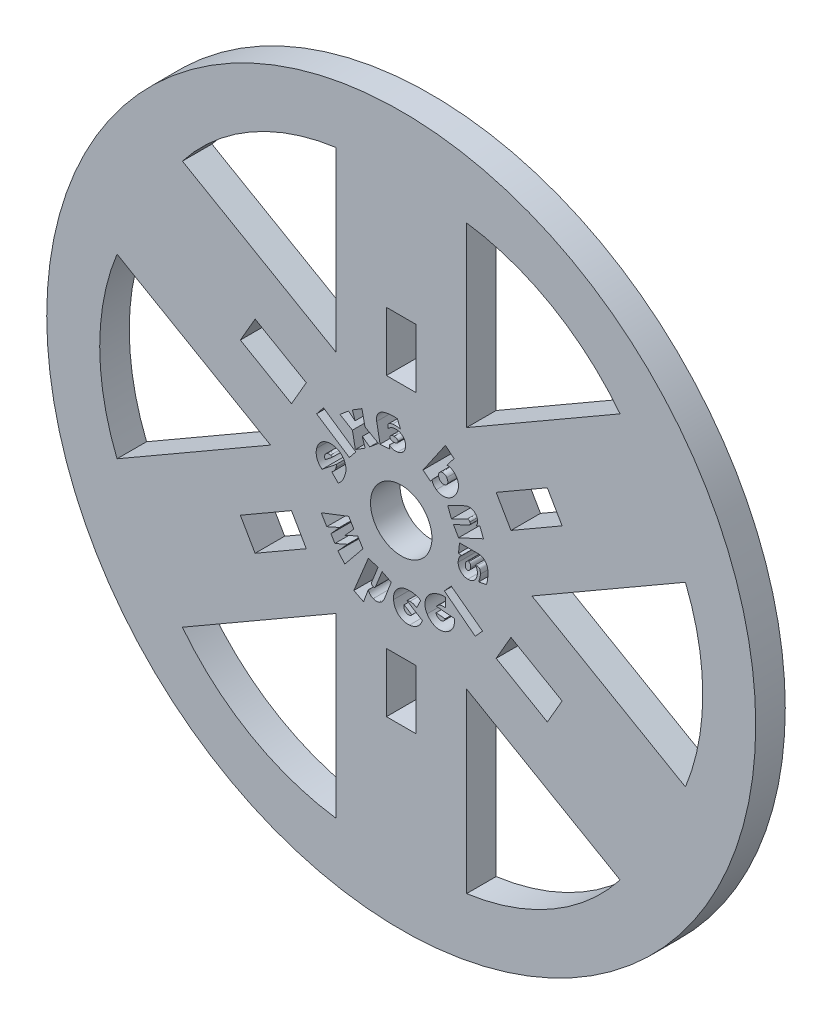
from build123d import *

# Parameters (mm, degrees)
SKETCH1_R          = 38.1
EXTRUDE1_DEPTH     = 3.175
SKETCH2_R          = 3.302
CUT_EXTRUDE1_DEPTH = 4.175
SKETCH3_W          = 3.175
SKETCH3_H          = 6.35
CUT_EXTRUDE2_DEPTH = 4.175
CUT_EXTRUDE3_DEPTH = 4.175
CUT_EXTRUDE4_DEPTH = 4.175


with BuildPart() as part:
    # Sketch1 → Extrude1 (new body)
    with BuildSketch(Plane.XY):
        Circle(SKETCH1_R)
    extrude(amount=EXTRUDE1_DEPTH)

    # Sketch2 → Cut-Extrude1 (cut, through all)
    with BuildSketch(Plane.XY.offset(3.175)):
        Circle(SKETCH2_R)
    extrude(amount=-CUT_EXTRUDE1_DEPTH, mode=Mode.SUBTRACT)

    # Sketch3 → Cut-Extrude2 (cut, through all)
    with BuildSketch(Plane.XY.offset(3.175)):
        with Locations((0, 15.875)):
            Rectangle(SKETCH3_W, SKETCH3_H)
        Polygon((-17.291533942, 8.150184671), (-15.704033942, 10.899815329), (-10.204772628, 7.724815329), (-11.792272628, 4.975184671), align=None)
        Polygon((-11.792272628, -4.975184671), (-10.204772628, -7.724815329), (-15.704033942, -10.899815329), (-17.291533942, -8.150184671), align=None)
        with Locations((0, -15.875)):
            Rectangle(SKETCH3_W, SKETCH3_H)
        Polygon((10.204772628, -7.724815329), (11.792272628, -4.975184671), (17.291533942, -8.150184671), (15.704033942, -10.899815329), align=None)
        Polygon((11.792272628, 4.975184671), (10.204772628, 7.724815329), (15.704033942, 10.899815329), (17.291533942, 8.150184671), align=None)
    extrude(amount=-CUT_EXTRUDE2_DEPTH, mode=Mode.SUBTRACT)

    # Sketch4 → Cut-Extrude3 (cut, through all)
    with BuildSketch(Plane.XY.offset(3.175)):
        with BuildLine():
            Line((7.02309032, 31.21434926), (7.02309032, 12.16434926))
            Line((7.02309032, 12.16434926), (23.520874262, 21.68934926))
            ThreePointArc((23.520874262, 21.68934926), (16.202768265, 28.064017859), (7.02309032, 31.21434926))
        make_face()
        with BuildLine():
            Line((30.543964582, 9.525), (14.04618064, 0))
            Line((14.04618064, 0), (30.543964582, -9.525))
            ThreePointArc((30.543964582, -9.525), (32.405536531, 0), (30.543964582, 9.525))
        make_face()
        with BuildLine():
            Line((23.520874262, -21.68934926), (7.02309032, -12.16434926))
            Line((7.02309032, -12.16434926), (7.02309032, -31.21434926))
            ThreePointArc((7.02309032, -31.21434926), (16.202768265, -28.064017859), (23.520874262, -21.68934926))
        make_face()
        with BuildLine():
            Line((-7.02309032, -31.21434926), (-7.02309032, -12.16434926))
            Line((-7.02309032, -12.16434926), (-23.520874262, -21.68934926))
            ThreePointArc((-23.520874262, -21.68934926), (-16.202768265, -28.064017859), (-7.02309032, -31.21434926))
        make_face()
        with BuildLine():
            Line((-30.543964582, -9.525), (-14.04618064, 0))
            Line((-14.04618064, 0), (-30.543964582, 9.525))
            ThreePointArc((-30.543964582, 9.525), (-32.405536531, 0), (-30.543964582, -9.525))
        make_face()
        with BuildLine():
            Line((-23.520874262, 21.68934926), (-7.02309032, 12.16434926))
            Line((-7.02309032, 12.16434926), (-7.02309032, 31.21434926))
            ThreePointArc((-7.02309032, 31.21434926), (-16.202768265, 28.064017859), (-23.520874262, 21.68934926))
        make_face()
    extrude(amount=-CUT_EXTRUDE3_DEPTH, mode=Mode.SUBTRACT)

    # Sketch5 → Cut-Extrude4 (cut, through all)
    with BuildSketch(Plane(origin=(0, 0, 0), x_dir=(-1, 0, 0), z_dir=(0, 0, -1))):
        with BuildLine():
            Line((6.770458386, 0.087976317), (7.468288285, 0.798603528))
            add(Edge.make_bspline(
                [(7.468288285, 0.798603528), (7.443432949, 0.816071539), (7.393779198, 0.850967557), (7.324020642, 0.909581033), (7.256485804, 0.971425153), (7.192046159, 1.038166748), (7.132118874, 1.113416826), (7.083642134, 1.201761147), (7.040063681, 1.300341562), (7.020679234, 1.371892512), (7.010596183, 1.409110592)],
                knots=[0, 0, 0, 0, 9.1099e-05, 0.00018199, 0.000273089, 0.000365733, 0.000460147, 0.000560614, 0.00066717, 0.00078268, 0.00078268, 0.00078268, 0.00078268], degree=3))
            add(Edge.make_bspline(
                [(7.010596183, 1.409110592), (7.004313634, 1.435914652), (6.991174223, 1.491973044), (6.976565307, 1.577084273), (6.968523466, 1.660128705), (6.977283986, 1.712281624), (6.981237644, 1.735818441)],
                knots=[0, 0, 0, 0, 8.2549e-05, 0.000172644, 0.000259375, 0.000330711, 0.000330711, 0.000330711, 0.000330711], degree=3))
            Line((6.981237644, 1.735818441), (8.505623346, 0.513298747))
            add(Edge.make_bspline(
                [(8.505623346, 0.513298747), (8.536892713, 0.537917212), (8.59872412, 0.586597262), (8.683756745, 0.667407906), (8.763170949, 0.751254325), (8.834811641, 0.840613307), (8.899695636, 0.934181701), (8.958024431, 1.032072776), (9.008140606, 1.135167048), (9.052983807, 1.241620671), (9.088984992, 1.352146806), (9.116088932, 1.465178438), (9.13435856, 1.580453726), (9.143165897, 1.697750932), (9.143483995, 1.81733511), (9.132919304, 1.93848591), (9.115533189, 2.062200229), (9.095979254, 2.144209658), (9.086019087, 2.185982713)],
                knots=[0, 0, 0, 0, 0.000119332, 0.000235965, 0.000351534, 0.000465572, 0.00057917, 0.00069291, 0.000807038, 0.000922793, 0.001039202, 0.001155326, 0.001271167, 0.001388948, 0.001507888, 0.00162948, 0.001753507, 0.00188227, 0.00188227, 0.00188227, 0.00188227], degree=3))
            add(Edge.make_bspline(
                [(9.086019087, 2.185982713), (9.071422161, 2.23724209), (9.042573392, 2.338549032), (8.982969933, 2.483518838), (8.912332231, 2.620751647), (8.8284284, 2.748360979), (8.734765815, 2.867089294), (8.629232195, 2.97379248), (8.513773118, 3.068987104), (8.388068194, 3.152123672), (8.253228429, 3.222926471), (8.109327236, 3.28066698), (7.956495356, 3.3231535), (7.79581487, 3.352587434), (7.627658551, 3.367385692), (7.452872694, 3.36289688), (7.271763068, 3.341321972), (7.150891825, 3.313082669), (7.088885622, 3.29859608)],
                knots=[0, 0, 0, 0, 0.000159783, 0.000315789, 0.000469322, 0.000622159, 0.000773231, 0.000922278, 0.001071483, 0.001221391, 0.001373589, 0.001527636, 0.001685636, 0.001848644, 0.002017123, 0.002191057, 0.002372291, 0.002563197, 0.002563197, 0.002563197, 0.002563197], degree=3))
            add(Edge.make_bspline(
                [(7.088885622, 3.29859608), (7.039323678, 3.284647443), (6.940900112, 3.256947266), (6.800714387, 3.196056861), (6.667363421, 3.124093705), (6.543319886, 3.038016016), (6.429135279, 2.940693748), (6.324376124, 2.834618596), (6.232423188, 2.717826014), (6.151663093, 2.592616454), (6.082924704, 2.45939083), (6.028054757, 2.318146269), (5.984862514, 2.170408096), (5.955505075, 2.015930918), (5.941023481, 1.856075853), (5.943468103, 1.691863792), (5.963043063, 1.524174215), (5.988288213, 1.412932501), (6.001114096, 1.356415778)],
                knots=[0, 0, 0, 0, 0.000154304, 0.000306428, 0.000457345, 0.000608317, 0.000758393, 0.000906913, 0.001054811, 0.001203483, 0.001353304, 0.00150372, 0.001657378, 0.001814466, 0.001974696, 0.002138065, 0.002306325, 0.002480094, 0.002480094, 0.002480094, 0.002480094], degree=3))
            add(Edge.make_bspline(
                [(6.001114096, 1.356415778), (6.01946971, 1.288868608), (6.055254323, 1.157184136), (6.123518122, 0.97005764), (6.199224575, 0.796980572), (6.286004679, 0.63775596), (6.384822656, 0.488542492), (6.499928701, 0.349016824), (6.626810223, 0.212620042), (6.721978619, 0.130042283), (6.770458386, 0.087976317)],
                knots=[0, 0, 0, 0, 0.000209908, 0.000409219, 0.00059694, 0.000776154, 0.000952577, 0.001132927, 0.001318243, 0.001510668, 0.001510668, 0.001510668, 0.001510668], degree=3))
        make_face()
        with BuildLine():
            Line((8.154073655, 1.592789659), (7.39075163, 2.201038374))
            add(Edge.make_bspline(
                [(7.39075163, 2.201038374), (7.402432849, 2.210707578), (7.424944062, 2.229341377), (7.455187998, 2.25115748), (7.483463301, 2.266396659), (7.511593467, 2.277326436), (7.546508933, 2.288698766), (7.572375665, 2.295301256), (7.586475226, 2.298900172)],
                knots=[0, 0, 0, 0, 4.5498e-05, 8.7681e-05, 0.000111593, 0.000141648, 0.00017807, 0.000221712, 0.000221712, 0.000221712, 0.000221712], degree=3))
            add(Edge.make_bspline(
                [(7.586475226, 2.298900172), (7.618450924, 2.305719808), (7.682682595, 2.319418855), (7.781821601, 2.316369945), (7.878817925, 2.29888569), (7.970388841, 2.264518449), (8.05476936, 2.216357615), (8.112822795, 2.16028213), (8.153622281, 2.110664088), (8.178306713, 2.068550194), (8.199207126, 2.023316752), (8.208213231, 1.99091792), (8.212790734, 1.974450672)],
                knots=[0, 0, 0, 0, 9.7769e-05, 0.000196395, 0.000295171, 0.000392352, 0.000488535, 0.000584402, 0.000632604, 0.000680887, 0.000730417, 0.000781612, 0.000781612, 0.000781612, 0.000781612], degree=3))
            add(Edge.make_bspline(
                [(8.212790734, 1.974450672), (8.22009815, 1.940490904), (8.234072655, 1.875547161), (8.233917721, 1.793150083), (8.224754003, 1.730248886), (8.207917921, 1.684252509), (8.18540939, 1.637330186), (8.164825182, 1.608071849), (8.154073655, 1.592789659)],
                knots=[0, 0, 0, 0, 0.00010396, 0.000198811, 0.000245344, 0.000293908, 0.000345081, 0.000401036, 0.000401036, 0.000401036, 0.000401036], degree=3))
        make_face(mode=Mode.SUBTRACT)
        Polygon((4.883680548, 3.940329055), (5.573982616, 3.082156363), (9.090232303, 5.389436451), (8.354010467, 6.316112401), align=None)
        Polygon((5.247492465, 7.670248568), (4.219943584, 8.303339123), (3.899257999, 6.771425591), (2.446386688, 5.950139269), (3.383601601, 5.157458704), (4.180046082, 5.738607228), (4.188326696, 5.732584964), (3.874416158, 4.799886749), (4.932076362, 4.137437654), (5.244481333, 5.79054926), (6.584435185, 6.578713126), (5.670556546, 7.361607512), (4.964446033, 6.797020215), (4.95616542, 6.803042479), align=None)
        with BuildLine():
            Line((1.224065456, 6.042364259), (2.273445046, 5.967085952))
            Line((2.273445046, 5.967085952), (2.636286482, 7.907007905))
            add(Edge.make_bspline(
                [(2.636286482, 7.907007905), (2.643729032, 7.956580103), (2.658071611, 8.052110955), (2.659977225, 8.192399211), (2.647306066, 8.322787293), (2.617396757, 8.443116222), (2.574017736, 8.553770533), (2.519268941, 8.656049454), (2.454708233, 8.750762912), (2.378288758, 8.836090892), (2.293308404, 8.914276753), (2.197481528, 8.982319384), (2.094059673, 9.043955631), (1.981888079, 9.095901465), (1.8645151, 9.140145743), (1.744149438, 9.179227503), (1.621131086, 9.210086751), (1.537575822, 9.224635529), (1.495820142, 9.231906096)],
                knots=[0, 0, 0, 0, 0.000150234, 0.000289518, 0.000419703, 0.000542213, 0.000660198, 0.000775374, 0.000889591, 0.001003182, 0.001118281, 0.001235283, 0.001355091, 0.001479017, 0.001605541, 0.00173124, 0.001858496, 0.001985618, 0.001985618, 0.001985618, 0.001985618], degree=3))
            add(Edge.make_bspline(
                [(1.495820142, 9.231906096), (1.40384902, 9.244937071), (1.221161709, 9.270821217), (0.992221367, 9.288489494), (0.811068175, 9.293699016), (0.677419437, 9.292647666), (0.545306352, 9.284159919), (0.458200558, 9.274403664), (0.414823664, 9.269545249)],
                knots=[0, 0, 0, 0, 0.000278624, 0.000553447, 0.000688248, 0.000822251, 0.000954248, 0.001085183, 0.001085183, 0.001085183, 0.001085183], degree=3))
            Line((0.414823664, 9.269545249), (0.085104682, 8.481381382))
            add(Edge.make_bspline(
                [(0.085104682, 8.481381382), (0.154559771, 8.490577332), (0.291963454, 8.508769771), (0.464240635, 8.525418818), (0.602463756, 8.532198429), (0.708809818, 8.530605966), (0.818135632, 8.522278499), (0.891631266, 8.512131639), (0.928974496, 8.506976006)],
                knots=[0, 0, 0, 0, 0.000210179, 0.000415799, 0.000519029, 0.000625182, 0.000734649, 0.000847722, 0.000847722, 0.000847722, 0.000847722], degree=3))
            add(Edge.make_bspline(
                [(0.928974496, 8.506976006), (0.968022628, 8.49991601), (1.042633824, 8.486426125), (1.147351531, 8.455748674), (1.238866588, 8.416659844), (1.306376019, 8.377591232), (1.351775925, 8.340397171), (1.379415089, 8.307992559), (1.401432038, 8.271692262), (1.417310729, 8.230887352), (1.427719496, 8.186027876), (1.432915749, 8.137002574), (1.432093269, 8.083676446), (1.426977508, 8.047236899), (1.424305751, 8.028205978)],
                knots=[0, 0, 0, 0, 0.000118992, 0.000227364, 0.000326506, 0.000417006, 0.000460283, 0.000501925, 0.000544141, 0.000587056, 0.000632704, 0.000681918, 0.000734618, 0.000792229, 0.000792229, 0.000792229, 0.000792229], degree=3))
            Line((1.424305751, 8.028205978), (1.39946391, 7.873132667))
            add(Edge.make_bspline(
                [(1.39946391, 7.873132667), (1.382206663, 7.89102346), (1.346891885, 7.927634707), (1.286436969, 7.977809097), (1.2203364, 8.027237269), (1.148067074, 8.07639916), (1.066408263, 8.120198958), (0.974189621, 8.157446491), (0.871043345, 8.186278391), (0.798114823, 8.199677341), (0.76035109, 8.206615564)],
                knots=[0, 0, 0, 0, 7.4522e-05, 0.000152499, 0.000235305, 0.00032216, 0.000414442, 0.000512715, 0.000619943, 0.000735097, 0.000735097, 0.000735097, 0.000735097], degree=3))
            add(Edge.make_bspline(
                [(0.76035109, 8.206615564), (0.723027778, 8.211633946), (0.64960952, 8.221505548), (0.539645997, 8.223188324), (0.432566133, 8.215915504), (0.328688367, 8.198692062), (0.229217304, 8.171823079), (0.133870995, 8.13878457), (0.044743741, 8.094829081), (-0.039741518, 8.045084099), (-0.117408966, 7.986407773), (-0.189607186, 7.921742862), (-0.254249877, 7.848759558), (-0.313096958, 7.770102153), (-0.3640245, 7.68486412), (-0.404401438, 7.592926664), (-0.436935844, 7.495804878), (-0.449193545, 7.427937532), (-0.455393557, 7.393609856)],
                knots=[0, 0, 0, 0, 0.000112892, 0.000222069, 0.000329229, 0.000434546, 0.000537347, 0.000638066, 0.000736715, 0.000834961, 0.000931769, 0.001028234, 0.001125258, 0.001223723, 0.001322616, 0.001422362, 0.001524488, 0.001629014, 0.001629014, 0.001629014, 0.001629014], degree=3))
            add(Edge.make_bspline(
                [(-0.455393557, 7.393609856), (-0.460788381, 7.354034261), (-0.471374176, 7.276378506), (-0.47202613, 7.160809975), (-0.463605304, 7.049303197), (-0.443016711, 6.94242418), (-0.41285448, 6.840707779), (-0.374284791, 6.74480534), (-0.328342552, 6.65458563), (-0.274061139, 6.57065932), (-0.211462844, 6.493914314), (-0.14166729, 6.424269028), (-0.065169781, 6.361281404), (0.018125598, 6.305954977), (0.106997629, 6.258228112), (0.200819659, 6.220274841), (0.298009315, 6.189089886), (0.365211905, 6.177114071), (0.39901522, 6.171090162)],
                knots=[0, 0, 0, 0, 0.000119709, 0.000234895, 0.000345922, 0.000454732, 0.000560725, 0.000663749, 0.000764414, 0.000864012, 0.000963005, 0.001060948, 0.001159358, 0.001259784, 0.00136048, 0.001461411, 0.001563082, 0.001665982, 0.001665982, 0.001665982, 0.001665982], degree=3))
            add(Edge.make_bspline(
                [(0.39901522, 6.171090162), (0.439846682, 6.165599551), (0.520259304, 6.154786456), (0.640504689, 6.151232134), (0.757799471, 6.158332057), (0.872174601, 6.173778903), (0.982711247, 6.203550237), (1.086275352, 6.250667309), (1.183253053, 6.3140413), (1.239640396, 6.367384431), (1.268479657, 6.394666732)],
                knots=[0, 0, 0, 0, 0.000123534, 0.000243286, 0.000360164, 0.000475779, 0.00058901, 0.000702211, 0.000815791, 0.000934695, 0.000934695, 0.000934695, 0.000934695], degree=3))
            Line((1.268479657, 6.394666732), (1.27901862, 6.393161166))
            Line((1.27901862, 6.393161166), (1.224065456, 6.042364259))
        make_face()
        with BuildLine():
            add(Edge.make_bspline(
                [(0.773148402, 7.449315803), (0.807849254, 7.448757833), (0.872906985, 7.447711741), (0.963348222, 7.432183313), (1.039957146, 7.405975136), (1.100177201, 7.366579228), (1.146396019, 7.321910564), (1.180540588, 7.275050752), (1.201766068, 7.225407423), (1.204605016, 7.191295579), (1.205998663, 7.174549985)],
                knots=[0, 0, 0, 0, 0.000103982, 0.000194948, 0.000274247, 0.000345033, 0.000408918, 0.000466149, 0.000518151, 0.000568295, 0.000568295, 0.000568295, 0.000568295], degree=3))
            add(Edge.make_bspline(
                [(1.205998663, 7.174549985), (1.205028493, 7.155788897), (1.203092542, 7.118351575), (1.18124133, 7.064758189), (1.145014613, 7.016086759), (1.094942916, 6.972918668), (1.032242051, 6.936322242), (0.956634272, 6.912624932), (0.870737127, 6.895966141), (0.809377593, 6.895016919), (0.776912317, 6.894514686)],
                knots=[0, 0, 0, 0, 5.6031e-05, 0.000111808, 0.00017053, 0.000236672, 0.000308849, 0.000386692, 0.000473213, 0.000570427, 0.000570427, 0.000570427, 0.000570427], degree=3))
            add(Edge.make_bspline(
                [(0.776912317, 6.894514686), (0.744205917, 6.895081804), (0.682411449, 6.896153301), (0.595304864, 6.912066953), (0.518349197, 6.934774442), (0.453854108, 6.969876389), (0.401595695, 7.011858872), (0.363574279, 7.060723072), (0.340217835, 7.115691031), (0.336773431, 7.15425999), (0.335028659, 7.173797202)],
                knots=[0, 0, 0, 0, 9.7966e-05, 0.000185094, 0.00026485, 0.000337605, 0.000403919, 0.000464596, 0.000521634, 0.000580187, 0.000580187, 0.000580187, 0.000580187], degree=3))
            add(Edge.make_bspline(
                [(0.335028659, 7.173797202), (0.336868552, 7.193407426), (0.34053557, 7.232491782), (0.367415674, 7.286852626), (0.409128541, 7.335058851), (0.466001032, 7.37513629), (0.532857608, 7.408419025), (0.607467088, 7.432478897), (0.688258691, 7.447141252), (0.744226712, 7.44857494), (0.773148402, 7.449315803)],
                knots=[0, 0, 0, 0, 5.8664e-05, 0.000116921, 0.000178322, 0.000248335, 0.000324082, 0.000401689, 0.000482755, 0.000569443, 0.000569443, 0.000569443, 0.000569443], degree=3))
        make_face(mode=Mode.SUBTRACT)
        with BuildLine():
            Line((-4.743809668, 9.369816882), (-5.676507883, 8.608000422))
            Line((-5.676507883, 8.608000422), (-4.928994301, 7.613573996))
            add(Edge.make_bspline(
                [(-4.928994301, 7.613573996), (-4.955327562, 7.615383055), (-5.008007186, 7.619002073), (-5.087673462, 7.614423531), (-5.167147993, 7.599782248), (-5.246138084, 7.576181251), (-5.323476376, 7.545170105), (-5.399749505, 7.509443435), (-5.47397744, 7.468597973), (-5.521159885, 7.436782553), (-5.544770847, 7.420861532)],
                knots=[0, 0, 0, 0, 7.9132e-05, 0.000158303, 0.000238629, 0.000321044, 0.000405198, 0.000488376, 0.00057363, 0.000659027, 0.000659027, 0.000659027, 0.000659027], degree=3))
            add(Edge.make_bspline(
                [(-5.544770847, 7.420861532), (-5.589969605, 7.387696733), (-5.678138176, 7.323002634), (-5.794526613, 7.211821221), (-5.895203349, 7.093960013), (-5.977927931, 6.967900894), (-6.044246417, 6.836587569), (-6.095269917, 6.701310683), (-6.130872214, 6.562491548), (-6.150294172, 6.420287978), (-6.154655598, 6.275989153), (-6.144561818, 6.130340805), (-6.121069008, 5.983162156), (-6.083229028, 5.835386783), (-6.032363075, 5.688201556), (-5.967382867, 5.543961706), (-5.891944399, 5.401639009), (-5.831867873, 5.311335908), (-5.801469871, 5.265643623)],
                knots=[0, 0, 0, 0, 0.000168033, 0.000327779, 0.000481612, 0.000632148, 0.000778931, 0.000922104, 0.001065064, 0.001207934, 0.001351786, 0.001497403, 0.001645295, 0.001798296, 0.001954469, 0.002111845, 0.002272499, 0.002437047, 0.002437047, 0.002437047, 0.002437047], degree=3))
            add(Edge.make_bspline(
                [(-5.801469871, 5.265643623), (-5.765955573, 5.216774244), (-5.696681975, 5.12145045), (-5.580452555, 4.993148598), (-5.459350387, 4.880050959), (-5.331614278, 4.78409497), (-5.199912598, 4.704785856), (-5.066696085, 4.638989608), (-4.931661612, 4.589203365), (-4.795404275, 4.554322437), (-4.659145786, 4.534056079), (-4.523525254, 4.527400204), (-4.388787428, 4.532936507), (-4.255938341, 4.553597594), (-4.126357977, 4.586667106), (-4.001949611, 4.631796305), (-3.883167508, 4.689109682), (-3.809647008, 4.736648593), (-3.772719517, 4.760526188)],
                knots=[0, 0, 0, 0, 0.000181121, 0.000353291, 0.000518427, 0.000677565, 0.000831584, 0.000979045, 0.001122661, 0.001262517, 0.001400278, 0.001535197, 0.001669327, 0.001804111, 0.001937759, 0.002069926, 0.002200555, 0.002332378, 0.002332378, 0.002332378, 0.002332378], degree=3))
            add(Edge.make_bspline(
                [(-3.772719517, 4.760526188), (-3.743189956, 4.782078941), (-3.683797032, 4.82542808), (-3.60224764, 4.900209071), (-3.526523001, 4.98228329), (-3.456937778, 5.06984025), (-3.396769887, 5.162956023), (-3.353005063, 5.261172662), (-3.324548122, 5.362508182), (-3.318710701, 5.431332648), (-3.315780198, 5.465883918)],
                knots=[0, 0, 0, 0, 0.000109607, 0.000220453, 0.000331253, 0.000444353, 0.000555668, 0.000662828, 0.000765825, 0.000869657, 0.000869657, 0.000869657, 0.000869657], degree=3))
            Line((-3.315780198, 5.465883918), (-3.306746801, 5.472658965))
            Line((-3.306746801, 5.472658965), (-3.136617829, 5.228757253))
            Line((-3.136617829, 5.228757253), (-2.33565665, 5.867870073))
            Line((-2.33565665, 5.867870073), (-4.743809668, 9.369816882))
        make_face()
        with BuildLine():
            add(Edge.make_bspline(
                [(-4.113730244, 5.891206348), (-4.126245603, 5.874665413), (-4.150551259, 5.84254182), (-4.190912089, 5.799218707), (-4.233093527, 5.7615379), (-4.290295304, 5.719013063), (-4.365472391, 5.677837621), (-4.460404317, 5.64875069), (-4.555562171, 5.640293942), (-4.648148028, 5.646920489), (-4.736956857, 5.673307497), (-4.789059775, 5.705067596), (-4.815324059, 5.721077376)],
                knots=[0, 0, 0, 0, 6.2195e-05, 0.000120786, 0.0001773, 0.000231652, 0.000334387, 0.000432737, 0.000527267, 0.000619415, 0.000709905, 0.000801887, 0.000801887, 0.000801887, 0.000801887], degree=3))
            add(Edge.make_bspline(
                [(-4.815324059, 5.721077376), (-4.838831301, 5.73971497), (-4.886853379, 5.777789023), (-4.942276637, 5.853462454), (-4.984067897, 5.938691226), (-5.007098813, 6.032922524), (-5.009938692, 6.132304908), (-4.998504299, 6.217348823), (-4.980707576, 6.286733308), (-4.957655121, 6.338461772), (-4.931319427, 6.391296112), (-4.907896212, 6.423966539), (-4.895871846, 6.440737984)],
                knots=[0, 0, 0, 0, 8.9654e-05, 0.000183151, 0.000278433, 0.000373009, 0.000471695, 0.000574967, 0.000629568, 0.000685911, 0.000744498, 0.000806299, 0.000806299, 0.000806299, 0.000806299], degree=3))
            add(Edge.make_bspline(
                [(-4.895871846, 6.440737984), (-4.883865496, 6.456783972), (-4.86036312, 6.488193921), (-4.820889376, 6.530395121), (-4.779656768, 6.567674902), (-4.721689326, 6.608286563), (-4.645560684, 6.647011878), (-4.550370684, 6.67517683), (-4.454679786, 6.686014363), (-4.361398688, 6.675009224), (-4.272744909, 6.650469708), (-4.221086028, 6.619339453), (-4.195783598, 6.604091909)],
                knots=[0, 0, 0, 0, 6.0081e-05, 0.000117609, 0.00017306, 0.000226529, 0.000329547, 0.000427681, 0.000523035, 0.000616143, 0.000708075, 0.000796331, 0.000796331, 0.000796331, 0.000796331], degree=3))
            add(Edge.make_bspline(
                [(-4.195783598, 6.604091909), (-4.171149113, 6.584815752), (-4.121976328, 6.546338703), (-4.067118766, 6.469987701), (-4.025682812, 6.385495363), (-4.004550009, 6.291860947), (-4.000538549, 6.193006697), (-4.014138183, 6.109337437), (-4.032036325, 6.041584594), (-4.054105126, 5.991172306), (-4.080060052, 5.939980618), (-4.102289657, 5.907779057), (-4.113730244, 5.891206348)],
                knots=[0, 0, 0, 0, 9.3409e-05, 0.000186453, 0.000279048, 0.000374179, 0.000472114, 0.000574104, 0.000627254, 0.000681917, 0.000738821, 0.000799161, 0.000799161, 0.000799161, 0.000799161], degree=3))
        make_face(mode=Mode.SUBTRACT)
        with BuildLine():
            Line((-8.448062244, 3.725970437), (-8.835745521, 2.715735567))
            Line((-8.835745521, 2.715735567), (-6.159601733, 1.47289073))
            Line((-6.159601733, 1.47289073), (-5.610070097, 2.434947484))
            Line((-5.610070097, 2.434947484), (-7.306090337, 3.228380833))
            add(Edge.make_bspline(
                [(-7.306090337, 3.228380833), (-7.320661648, 3.236195185), (-7.348758423, 3.251263021), (-7.381692441, 3.285324766), (-7.407180773, 3.324598126), (-7.420531339, 3.370815582), (-7.425441456, 3.418971298), (-7.423299224, 3.466972609), (-7.413558057, 3.513878893), (-7.401193279, 3.543213758), (-7.394918739, 3.558099814)],
                knots=[0, 0, 0, 0, 4.9317e-05, 9.5095e-05, 0.000140419, 0.000188514, 0.000237728, 0.000285207, 0.000332158, 0.00038053, 0.00038053, 0.00038053, 0.00038053], degree=3))
            add(Edge.make_bspline(
                [(-7.394918739, 3.558099814), (-7.386900224, 3.572992571), (-7.371261601, 3.602038129), (-7.339421251, 3.639337367), (-7.303305454, 3.670901173), (-7.261843231, 3.69379182), (-7.218444114, 3.709464302), (-7.173989155, 3.714373231), (-7.130044652, 3.707433571), (-7.103595486, 3.694803546), (-7.090041598, 3.688331284)],
                knots=[0, 0, 0, 0, 5.061e-05, 9.8706e-05, 0.000146227, 0.000193754, 0.000239938, 0.000283832, 0.000326529, 0.000371407, 0.000371407, 0.000371407, 0.000371407], degree=3))
            Line((-7.090041598, 3.688331284), (-5.396279707, 2.855753217))
            Line((-5.396279707, 2.855753217), (-4.994293551, 3.905885589))
            Line((-4.994293551, 3.905885589), (-6.803231251, 4.77610281))
            add(Edge.make_bspline(
                [(-6.803231251, 4.77610281), (-6.835656622, 4.790863835), (-6.899367262, 4.819866875), (-6.997123462, 4.854980665), (-7.095062876, 4.880094506), (-7.192085567, 4.898511661), (-7.288017438, 4.908541691), (-7.382068348, 4.909476947), (-7.474012647, 4.900853396), (-7.563421742, 4.884753462), (-7.649543567, 4.859092551), (-7.731766347, 4.824251823), (-7.809380235, 4.779489415), (-7.88298998, 4.725920496), (-7.950770942, 4.662295927), (-8.013334416, 4.58900375), (-8.069641391, 4.505509985), (-8.101371941, 4.444464002), (-8.117590479, 4.413261373)],
                knots=[0, 0, 0, 0, 0.000106855, 0.000209954, 0.000311107, 0.000409883, 0.000505986, 0.000600086, 0.000691549, 0.000782648, 0.000872201, 0.000960569, 0.001049925, 0.001140416, 0.00123309, 0.001328132, 0.001428977, 0.001534415, 0.001534415, 0.001534415, 0.001534415], degree=3))
            add(Edge.make_bspline(
                [(-8.117590479, 4.413261373), (-8.131974343, 4.381454551), (-8.160281955, 4.318858352), (-8.187850666, 4.220811889), (-8.207812156, 4.123035185), (-8.214809504, 4.022817055), (-8.207374077, 3.918156833), (-8.180869591, 3.808161668), (-8.139483043, 3.69044183), (-8.099993145, 3.612626126), (-8.079198543, 3.571649909)],
                knots=[0, 0, 0, 0, 0.00010458, 0.000205815, 0.00030473, 0.000403577, 0.000506232, 0.000618177, 0.000741986, 0.000879698, 0.000879698, 0.000879698, 0.000879698], degree=3))
            Line((-8.079198543, 3.571649909), (-8.088231939, 3.552830333))
            Line((-8.088231939, 3.552830333), (-8.448062244, 3.725970437))
        make_face()
        with BuildLine():
            Line((-6.146600771, 0.015202137), (-6.267798844, 1.058559462))
            Line((-6.267798844, 1.058559462), (-8.236326554, 1.054042764))
            add(Edge.make_bspline(
                [(-8.236326554, 1.054042764), (-8.286360316, 1.052168558), (-8.382728481, 1.04855872), (-8.520767288, 1.02499378), (-8.646158932, 0.987706857), (-8.758659438, 0.935827314), (-8.859184628, 0.872768404), (-8.949922032, 0.800816314), (-9.029714774, 0.718929062), (-9.100404489, 0.629107297), (-9.159687722, 0.530261382), (-9.210310767, 0.424730108), (-9.251137431, 0.311754823), (-9.281435776, 0.192610548), (-9.302459192, 0.06937491), (-9.318083833, -0.055425938), (-9.324676941, -0.181705571), (-9.323790722, -0.26608455), (-9.323345296, -0.30849458)],
                knots=[0, 0, 0, 0, 0.000150076, 0.000289056, 0.000418843, 0.000541451, 0.000659468, 0.000774094, 0.000888011, 0.001001703, 0.001116218, 0.001233055, 0.001352358, 0.001475966, 0.001601338, 0.001727204, 0.001853101, 0.001980321, 0.001980321, 0.001980321, 0.001980321], degree=3))
            add(Edge.make_bspline(
                [(-9.323345296, -0.30849458), (-9.318934885, -0.40113689), (-9.310179722, -0.585042314), (-9.286645563, -0.813170171), (-9.257110994, -0.991680231), (-9.231255321, -1.122731518), (-9.198903436, -1.250830652), (-9.172912688, -1.334396265), (-9.159991372, -1.375940963)],
                knots=[0, 0, 0, 0, 0.000278226, 0.000552311, 0.00068733, 0.000820938, 0.000952941, 0.001083449, 0.001083449, 0.001083449, 0.001083449], degree=3))
            Line((-9.159991372, -1.375940963), (-8.325907738, -1.552844982))
            add(Edge.make_bspline(
                [(-8.325907738, -1.552844982), (-8.348095772, -1.486217558), (-8.391911662, -1.354644844), (-8.44134125, -1.188819088), (-8.473245754, -1.054373705), (-8.491209085, -0.94981729), (-8.503259049, -0.841200682), (-8.50695732, -0.767468698), (-8.508834022, -0.730053095)],
                knots=[0, 0, 0, 0, 0.000210678, 0.000416038, 0.000518842, 0.000625027, 0.000734095, 0.000846464, 0.000846464, 0.000846464, 0.000846464], degree=3))
            add(Edge.make_bspline(
                [(-8.508834022, -0.730053095), (-8.509088724, -0.690382135), (-8.509575193, -0.614612349), (-8.498423851, -0.506573824), (-8.477622532, -0.409618482), (-8.451514761, -0.336560772), (-8.423709298, -0.284754711), (-8.396634282, -0.252167434), (-8.365304557, -0.223476192), (-8.328214394, -0.200377621), (-8.285815496, -0.182035396), (-8.238408542, -0.168939002), (-8.185962462, -0.159712442), (-8.14929505, -0.157556217), (-8.130184142, -0.156432401)],
                knots=[0, 0, 0, 0, 0.000118949, 0.000227188, 0.000325087, 0.000415837, 0.000458977, 0.000500714, 0.000542287, 0.000585936, 0.000631109, 0.000680432, 0.000733154, 0.000790543, 0.000790543, 0.000790543, 0.000790543], degree=3))
            Line((-8.130184142, -0.156432401), (-7.974358048, -0.15116292))
            add(Edge.make_bspline(
                [(-7.974358048, -0.15116292), (-7.988506886, -0.171519129), (-8.017479299, -0.213202302), (-8.055515214, -0.281935785), (-8.092203961, -0.355913446), (-8.126815833, -0.435992001), (-8.155256081, -0.523899279), (-8.173566809, -0.621203996), (-8.18340836, -0.727587311), (-8.182564459, -0.801547614), (-8.182126173, -0.839959422)],
                knots=[0, 0, 0, 0, 7.4328e-05, 0.0001522, 0.000235354, 0.000322042, 0.000413699, 0.000511876, 0.000618469, 0.000733647, 0.000733647, 0.000733647, 0.000733647], degree=3))
            add(Edge.make_bspline(
                [(-8.182126173, -0.839959422), (-8.180140761, -0.877431257), (-8.176228481, -0.951270002), (-8.1570344, -1.059370921), (-8.131623196, -1.163566071), (-8.094880493, -1.26235326), (-8.050883458, -1.355375774), (-7.99913853, -1.441870703), (-7.94119141, -1.521940225), (-7.876382641, -1.595337232), (-7.804498601, -1.660879746), (-7.726990904, -1.719154403), (-7.643282091, -1.768623417), (-7.55554908, -1.812367243), (-7.462106653, -1.844882599), (-7.364957176, -1.868995631), (-7.263532252, -1.88081703), (-7.194750064, -1.880977147), (-7.159846774, -1.881058398)],
                knots=[0, 0, 0, 0, 0.00011247, 0.000221623, 0.000328797, 0.000433823, 0.000537195, 0.00063712, 0.000735746, 0.000833333, 0.000930304, 0.001027112, 0.00112368, 0.001221652, 0.001320699, 0.001419841, 0.001521431, 0.001626092, 0.001626092, 0.001626092, 0.001626092], degree=3))
            add(Edge.make_bspline(
                [(-7.159846774, -1.881058398), (-7.120120425, -1.878837446), (-7.041979689, -1.87446889), (-6.928522008, -1.854573282), (-6.821148699, -1.825026949), (-6.72017218, -1.786052911), (-6.626327359, -1.737558682), (-6.538940182, -1.682715341), (-6.459977699, -1.619818898), (-6.387774625, -1.551101652), (-6.323746869, -1.475630342), (-6.267735215, -1.394278097), (-6.22119985, -1.306824428), (-6.181638907, -1.215128591), (-6.152152983, -1.119101096), (-6.130303139, -1.020525378), (-6.11996001, -0.919483132), (-6.120155271, -0.851519216), (-6.120253364, -0.81737593)],
                knots=[0, 0, 0, 0, 0.000119282, 0.000234625, 0.000344753, 0.000452955, 0.000558669, 0.000661208, 0.000761963, 0.000860994, 0.000959792, 0.001058346, 0.001156696, 0.00125653, 0.001357481, 0.001457587, 0.001559009, 0.001661399, 0.001661399, 0.001661399, 0.001661399], degree=3))
            add(Edge.make_bspline(
                [(-6.120253364, -0.81737593), (-6.122203012, -0.776396391), (-6.126049886, -0.695539182), (-6.145784821, -0.577040999), (-6.173393696, -0.462854667), (-6.210400761, -0.353552212), (-6.259673362, -0.25082271), (-6.324726428, -0.157924753), (-6.404231623, -0.074328026), (-6.467461297, -0.029469329), (-6.499656028, -0.006628571)],
                knots=[0, 0, 0, 0, 0.000122983, 0.000242659, 0.000359692, 0.000475152, 0.000588273, 0.000700205, 0.000814137, 0.000932326, 0.000932326, 0.000932326, 0.000932326], degree=3))
            Line((-6.499656028, -0.006628571), (-6.500408811, 0.003910391))
            Line((-6.500408811, 0.003910391), (-6.146600771, 0.015202137))
        make_face()
        with BuildLine():
            add(Edge.make_bspline(
                [(-7.442140422, -0.68714446), (-7.447741155, -0.65286547), (-7.458201806, -0.588841608), (-7.460654414, -0.497254874), (-7.448800924, -0.417431974), (-7.421832707, -0.350713896), (-7.386333333, -0.297377446), (-7.346717725, -0.255312424), (-7.302596282, -0.225037754), (-7.269847673, -0.215848129), (-7.253944657, -0.211385565)],
                knots=[0, 0, 0, 0, 0.000104118, 0.000194465, 0.000273793, 0.000344387, 0.000408484, 0.000464917, 0.000517115, 0.000566392, 0.000566392, 0.000566392, 0.000566392], degree=3))
            add(Edge.make_bspline(
                [(-7.253944657, -0.211385565), (-7.235122238, -0.208763801), (-7.197950499, -0.203586173), (-7.141136278, -0.215644291), (-7.086691651, -0.24223781), (-7.035090242, -0.283628415), (-6.986969526, -0.337800165), (-6.94931176, -0.407451661), (-6.91771359, -0.489048291), (-6.905246174, -0.549125504), (-6.898631051, -0.581002048)],
                knots=[0, 0, 0, 0, 5.6639e-05, 0.000111855, 0.000171114, 0.000237072, 0.000309092, 0.000386964, 0.000473223, 0.000570725, 0.000570725, 0.000570725, 0.000570725], degree=3))
            add(Edge.make_bspline(
                [(-6.898631051, -0.581002048), (-6.893615663, -0.61303747), (-6.884055139, -0.674104618), (-6.882074286, -0.762502277), (-6.892262583, -0.842109759), (-6.913851, -0.911717689), (-6.944963663, -0.97074499), (-6.986153817, -1.016359129), (-7.034648313, -1.051097699), (-7.072296111, -1.061356712), (-7.091343515, -1.066547124)],
                knots=[0, 0, 0, 0, 9.7202e-05, 0.000185291, 0.000264286, 0.000336902, 0.000402928, 0.000462631, 0.00052005, 0.000578849, 0.000578849, 0.000578849, 0.000578849], degree=3))
            add(Edge.make_bspline(
                [(-7.091343515, -1.066547124), (-7.110739468, -1.068237534), (-7.149681178, -1.071631411), (-7.20788934, -1.054831533), (-7.262943894, -1.022585166), (-7.312905871, -0.974512106), (-7.358749133, -0.915737952), (-7.394933766, -0.846510605), (-7.424572129, -0.770097502), (-7.436141445, -0.715470115), (-7.442140422, -0.68714446)],
                knots=[0, 0, 0, 0, 5.7984e-05, 0.000116416, 0.000178135, 0.000247916, 0.000323052, 0.000400854, 0.000481385, 0.000568112, 0.000568112, 0.000568112, 0.000568112], degree=3))
        make_face(mode=Mode.SUBTRACT)
        Polygon((-4.636482021, -4.228662281), (-5.374209423, -3.415656573), (-8.738396931, -5.918660257), (-7.950233064, -6.797910874), align=None)
        with BuildLine():
            Line((-4.743511394, -4.763682775), (-4.759319838, -5.751334154))
            add(Edge.make_bspline(
                [(-4.759319838, -5.751334154), (-4.699957295, -5.743903453), (-4.580275388, -5.728922283), (-4.427681502, -5.731688831), (-4.303293362, -5.749026336), (-4.207621797, -5.77929135), (-4.109190561, -5.820965477), (-4.046008705, -5.858915296), (-4.013311823, -5.878554491)],
                knots=[0, 0, 0, 0, 0.000179322, 0.000361534, 0.000455969, 0.000555039, 0.000661595, 0.000775881, 0.000775881, 0.000775881, 0.000775881], degree=3))
            add(Edge.make_bspline(
                [(-4.013311823, -5.878554491), (-3.99055164, -5.893629689), (-3.942838017, -5.925232788), (-3.874764129, -5.977211788), (-3.811305553, -6.030585946), (-3.781955506, -6.07412389), (-3.768657328, -6.093850447)],
                knots=[0, 0, 0, 0, 8.1846e-05, 0.000171579, 0.00025736, 0.000328425, 0.000328425, 0.000328425, 0.000328425], degree=3))
            Line((-3.768657328, -6.093850447), (-5.70105145, -6.254946023))
            add(Edge.make_bspline(
                [(-5.70105145, -6.254946023), (-5.70655226, -6.294033758), (-5.717450617, -6.371475452), (-5.725216283, -6.487695096), (-5.723348834, -6.60241229), (-5.714320456, -6.715560861), (-5.698097792, -6.827678388), (-5.672134819, -6.937970232), (-5.638879521, -7.047179754), (-5.597709747, -7.15450433), (-5.548242142, -7.258750137), (-5.490804901, -7.358829751), (-5.424926523, -7.453665829), (-5.351976049, -7.544475537), (-5.270049565, -7.629735917), (-5.180158349, -7.710392636), (-5.082281386, -7.786620885), (-5.012328796, -7.83274044), (-4.976874143, -7.856115597)],
                knots=[0, 0, 0, 0, 0.000118395, 0.000234568, 0.000349001, 0.000462279, 0.000574915, 0.000688496, 0.000801844, 0.00091718, 0.001033013, 0.001147673, 0.001262938, 0.001379093, 0.001496761, 0.00161723, 0.001741156, 0.001868519, 0.001868519, 0.001868519, 0.001868519], degree=3))
            add(Edge.make_bspline(
                [(-4.976874143, -7.856115597), (-4.931396209, -7.883026455), (-4.841447164, -7.936252398), (-4.700134149, -8.001117916), (-4.555382658, -8.051159749), (-4.407909116, -8.086544098), (-4.258873263, -8.107229421), (-4.109790685, -8.11128184), (-3.961442995, -8.101925654), (-3.814260314, -8.076223867), (-3.669200226, -8.034174755), (-3.526174871, -7.978079706), (-3.387449732, -7.903796117), (-3.25138976, -7.815966659), (-3.120755408, -7.711020808), (-2.997780343, -7.588311175), (-2.882840209, -7.448197696), (-2.814510862, -7.345601789), (-2.779500383, -7.293033866)],
                knots=[0, 0, 0, 0, 0.000158451, 0.000313395, 0.000465519, 0.000617247, 0.000767677, 0.000916044, 0.001063914, 0.001212921, 0.001363269, 0.001516338, 0.001672918, 0.001834529, 0.002001589, 0.002174586, 0.002354829, 0.002544222, 0.002544222, 0.002544222, 0.002544222], degree=3))
            add(Edge.make_bspline(
                [(-2.779500383, -7.293033866), (-2.753132726, -7.248907203), (-2.701033345, -7.161718123), (-2.641229801, -7.022304554), (-2.594660712, -6.879567791), (-2.563934497, -6.732867512), (-2.548707457, -6.584577117), (-2.545426214, -6.436555121), (-2.559908075, -6.289888945), (-2.586827375, -6.144649379), (-2.628112396, -6.001818805), (-2.684334733, -5.862090491), (-2.755478778, -5.726782369), (-2.839837656, -5.595403481), (-2.93823054, -5.470197762), (-3.052339387, -5.353808946), (-3.180049493, -5.2455626), (-3.274406255, -5.1830618), (-3.322256971, -5.151366053)],
                knots=[0, 0, 0, 0, 0.000154063, 0.000304411, 0.000453914, 0.000603916, 0.000753054, 0.000900617, 0.001047284, 0.001194337, 0.001343238, 0.001492532, 0.001645397, 0.001801171, 0.001960357, 0.00212219, 0.002289418, 0.002461481, 0.002461481, 0.002461481, 0.002461481], degree=3))
            add(Edge.make_bspline(
                [(-3.322256971, -5.151366053), (-3.381755225, -5.115153602), (-3.497444686, -5.04474147), (-3.674337401, -4.955638224), (-3.847420105, -4.883801698), (-4.018713629, -4.828159577), (-4.191657216, -4.789665098), (-4.36964729, -4.765379592), (-4.554531131, -4.756438218), (-4.67978413, -4.761239791), (-4.743511394, -4.763682775)],
                knots=[0, 0, 0, 0, 0.000208892, 0.000406172, 0.0005935, 0.000770621, 0.000945762, 0.001124299, 0.001308952, 0.001500212, 0.001500212, 0.001500212, 0.001500212], degree=3))
        make_face()
        with BuildLine():
            Line((-4.710388939, -6.792433129), (-3.746073836, -6.708121426))
            add(Edge.make_bspline(
                [(-3.746073836, -6.708121426), (-3.747932067, -6.72319748), (-3.751542285, -6.752487617), (-3.758210244, -6.789049883), (-3.767234077, -6.819793636), (-3.780989128, -6.846393754), (-3.797838531, -6.878918368), (-3.812121084, -6.901445944), (-3.819846576, -6.913631203)],
                knots=[0, 0, 0, 0, 4.5567e-05, 8.8528e-05, 0.000111386, 0.000141356, 0.000178065, 0.000221316, 0.000221316, 0.000221316, 0.000221316], degree=3))
            add(Edge.make_bspline(
                [(-3.819846576, -6.913631203), (-3.838547276, -6.940194225), (-3.876089857, -6.993520807), (-3.94818492, -7.060473126), (-4.030919017, -7.11305488), (-4.120086338, -7.152064032), (-4.214487289, -7.172757033), (-4.294380938, -7.173841261), (-4.357647007, -7.165719755), (-4.403628391, -7.151064679), (-4.449751815, -7.133718037), (-4.478259544, -7.116600753), (-4.492834634, -7.107849233)],
                knots=[0, 0, 0, 0, 9.7261e-05, 0.000195256, 0.000292772, 0.000390234, 0.000485766, 0.000580628, 0.000628535, 0.000676413, 0.000725059, 0.000775948, 0.000775948, 0.000775948, 0.000775948], degree=3))
            add(Edge.make_bspline(
                [(-4.492834634, -7.107849233), (-4.521440869, -7.088246762), (-4.576000947, -7.050859376), (-4.633035088, -6.99176639), (-4.667523162, -6.938899977), (-4.687560533, -6.894772093), (-4.70206917, -6.845292838), (-4.707532345, -6.810582519), (-4.710388939, -6.792433129)],
                knots=[0, 0, 0, 0, 0.000103887, 0.000198141, 0.000243869, 0.000292713, 0.00034297, 0.000398046, 0.000398046, 0.000398046, 0.000398046], degree=3))
        make_face(mode=Mode.SUBTRACT)
        with BuildLine():
            Line((-2.092829682, -6.393825212), (-1.656968289, -7.29038984))
            add(Edge.make_bspline(
                [(-1.656968289, -7.29038984), (-1.632061397, -7.273047788), (-1.58239366, -7.238465375), (-1.504333481, -7.191443807), (-1.422920239, -7.149678874), (-1.338399528, -7.110771701), (-1.247063335, -7.08070845), (-1.147331007, -7.062897179), (-1.039398024, -7.057054002), (-0.96514165, -7.061999349), (-0.926768718, -7.064554921)],
                knots=[0, 0, 0, 0, 9.1034e-05, 0.000181534, 0.000273114, 0.000365446, 0.000460431, 0.000560687, 0.000668503, 0.000783799, 0.000783799, 0.000783799, 0.000783799], degree=3))
            add(Edge.make_bspline(
                [(-0.926768718, -7.064554921), (-0.899605035, -7.06744983), (-0.842467464, -7.073539138), (-0.758055223, -7.089977374), (-0.677073672, -7.109223027), (-0.630819952, -7.134427145), (-0.609847048, -7.145855492)],
                knots=[0, 0, 0, 0, 8.1887e-05, 0.000172246, 0.000258278, 0.00032965, 0.00032965, 0.00032965, 0.00032965], degree=3))
            Line((-0.609847048, -7.145855492), (-2.2742504, -8.171898806))
            add(Edge.make_bspline(
                [(-2.2742504, -8.171898806), (-2.26149365, -8.209740066), (-2.236238824, -8.284655258), (-2.189197562, -8.392529048), (-2.135385698, -8.495110572), (-2.076172949, -8.59336737), (-2.009413285, -8.68622407), (-1.936490318, -8.774521129), (-1.856427009, -8.857251094), (-1.770590958, -8.934925599), (-1.679170808, -9.006495688), (-1.581702592, -9.069977149), (-1.478938204, -9.124770664), (-1.37137654, -9.172637586), (-1.258620268, -9.21247187), (-1.140724321, -9.243733379), (-1.018120295, -9.268631175), (-0.934144738, -9.27765783), (-0.891387914, -9.282253824)],
                knots=[0, 0, 0, 0, 0.000119759, 0.000237089, 0.000352579, 0.000467094, 0.000580944, 0.000695352, 0.000810348, 0.000926005, 0.001042404, 0.001158286, 0.001274481, 0.001391424, 0.001511183, 0.001632799, 0.001757106, 0.001886052, 0.001886052, 0.001886052, 0.001886052], degree=3))
            add(Edge.make_bspline(
                [(-0.891387914, -9.282253824), (-0.838217644, -9.285694088), (-0.733150068, -9.292492253), (-0.576533021, -9.286386977), (-0.423816501, -9.265117036), (-0.275223314, -9.229881074), (-0.132028402, -9.180060897), (0.00430527, -9.117023006), (0.13300868, -9.040096821), (0.253322419, -8.9497372), (0.365445547, -8.845932185), (0.46765929, -8.72940072), (0.559361154, -8.599675026), (0.641581034, -8.458603662), (0.7110481, -8.304341334), (0.76593338, -8.13787336), (0.806070842, -7.959551041), (0.820558033, -7.836081574), (0.827968602, -7.772923783)],
                knots=[0, 0, 0, 0, 0.000159767, 0.00031571, 0.000469226, 0.000621686, 0.000773099, 0.000923311, 0.001071519, 0.001222076, 0.001373893, 0.001529122, 0.001686201, 0.001849791, 0.002018253, 0.002192744, 0.002374826, 0.0025655, 0.0025655, 0.0025655, 0.0025655], degree=3))
            add(Edge.make_bspline(
                [(0.827968602, -7.772923783), (0.831289265, -7.72125264), (0.83785175, -7.619137187), (0.829071042, -7.466411756), (0.804841737, -7.316900954), (0.765786079, -7.170826598), (0.71206872, -7.030458478), (0.646808642, -6.896426144), (0.567572728, -6.77065079), (0.476648824, -6.652632901), (0.373989882, -6.542980341), (0.259726792, -6.443522105), (0.134714449, -6.35317286), (-0.00123709, -6.274020788), (-0.146751447, -6.205175756), (-0.302594391, -6.153331073), (-0.466755663, -6.113737508), (-0.580038525, -6.100801858), (-0.637700022, -6.094217553)],
                knots=[0, 0, 0, 0, 0.000155221, 0.000306757, 0.000457742, 0.000608937, 0.000759513, 0.000907981, 0.001055442, 0.001204656, 0.001354309, 0.001505288, 0.001658431, 0.001816331, 0.001976638, 0.00214042, 0.002308225, 0.002482184, 0.002482184, 0.002482184, 0.002482184], degree=3))
            add(Edge.make_bspline(
                [(-0.637700022, -6.094217553), (-0.707667733, -6.08898913), (-0.843719366, -6.078822505), (-1.043211964, -6.079922679), (-1.231808395, -6.093373618), (-1.411071861, -6.122452732), (-1.584771413, -6.165761882), (-1.755742685, -6.225943833), (-1.926704868, -6.300965604), (-2.036845792, -6.36253162), (-2.092829682, -6.393825212)],
                knots=[0, 0, 0, 0, 0.000210416, 0.000409152, 0.000597891, 0.000777093, 0.000953279, 0.001134214, 0.001320253, 0.001512568, 0.001512568, 0.001512568, 0.001512568], degree=3))
        make_face()
        with BuildLine():
            Line((-1.138300759, -8.205021261), (-0.30798104, -7.68861208))
            add(Edge.make_bspline(
                [(-0.30798104, -7.68861208), (-0.302698566, -7.702828612), (-0.292453073, -7.730401934), (-0.283238329, -7.766600872), (-0.277814892, -7.798349279), (-0.276584834, -7.828396446), (-0.278692119, -7.865042361), (-0.280592883, -7.891616118), (-0.281633633, -7.906166385)],
                knots=[0, 0, 0, 0, 4.5473e-05, 8.8197e-05, 0.000111835, 0.000141983, 0.000178148, 0.000221914, 0.000221914, 0.000221914, 0.000221914], degree=3))
            add(Edge.make_bspline(
                [(-0.281633633, -7.906166385), (-0.286273435, -7.938544637), (-0.295619499, -8.003764933), (-0.330244273, -8.096710108), (-0.379375734, -8.182620052), (-0.442385136, -8.257886752), (-0.51743457, -8.319606647), (-0.588567585, -8.357632098), (-0.649550031, -8.37751155), (-0.697467404, -8.387550357), (-0.747343774, -8.391447684), (-0.780986349, -8.389125082), (-0.798042814, -8.387947545)],
                knots=[0, 0, 0, 0, 9.7899e-05, 0.000197201, 0.000295335, 0.000393647, 0.000489939, 0.000585233, 0.000633558, 0.000681983, 0.000731809, 0.000783048, 0.000783048, 0.000783048, 0.000783048], degree=3))
            add(Edge.make_bspline(
                [(-0.798042814, -8.387947545), (-0.83235523, -8.383261506), (-0.898295038, -8.374256121), (-0.976967561, -8.348355032), (-1.031951712, -8.316070817), (-1.070453925, -8.285970308), (-1.106142543, -8.248282889), (-1.127306134, -8.21981205), (-1.138300759, -8.205021261)],
                knots=[0, 0, 0, 0, 0.000103832, 0.000199539, 0.00024576, 0.000294552, 0.000345664, 0.000400926, 0.000400926, 0.000400926, 0.000400926], degree=3))
        make_face(mode=Mode.SUBTRACT)
        with BuildLine():
            Line((4.048221401, -9.581777644), (5.093084292, -9.061604548))
            Line((5.093084292, -9.061604548), (3.533317786, -5.278869657))
            Line((3.533317786, -5.278869657), (2.486949328, -5.598049676))
            Line((2.486949328, -5.598049676), (3.191554275, -7.352034212))
            add(Edge.make_bspline(
                [(3.191554275, -7.352034212), (3.196963138, -7.367677941), (3.207328487, -7.397657018), (3.212161584, -7.444212687), (3.206149791, -7.488953328), (3.189030404, -7.530588062), (3.164013788, -7.567797174), (3.133442731, -7.601099638), (3.096175272, -7.628632839), (3.067626802, -7.641370595), (3.053042191, -7.647877956)],
                knots=[0, 0, 0, 0, 4.9535e-05, 9.4927e-05, 0.000139002, 0.000183595, 0.000228693, 0.000272902, 0.000318674, 0.00036648, 0.00036648, 0.00036648, 0.00036648], degree=3))
            add(Edge.make_bspline(
                [(3.053042191, -7.647877956), (3.037404413, -7.65359264), (3.00747536, -7.664529941), (2.961054549, -7.669328332), (2.91658295, -7.667129796), (2.875080494, -7.653573074), (2.837405288, -7.633842168), (2.806136495, -7.606441254), (2.779212051, -7.574425303), (2.767658471, -7.548862927), (2.761715146, -7.53571328)],
                knots=[0, 0, 0, 0, 4.9758e-05, 9.5231e-05, 0.000138996, 0.000182332, 0.000225108, 0.000265689, 0.000306367, 0.00034946, 0.00034946, 0.00034946, 0.00034946], degree=3))
            Line((2.761715146, -7.53571328), (2.055604633, -5.777212045))
            Line((2.055604633, -5.777212045), (1.073222736, -6.2725433))
            Line((1.073222736, -6.2725433), (1.793636127, -8.149231476))
            add(Edge.make_bspline(
                [(1.793636127, -8.149231476), (1.806931587, -8.18232452), (1.83315924, -8.247606421), (1.880843004, -8.340653208), (1.935157759, -8.426962389), (1.994342115, -8.507425083), (2.060198826, -8.579197722), (2.12899548, -8.644501012), (2.202868375, -8.700326145), (2.27955766, -8.748909534), (2.3603053, -8.788663296), (2.445315438, -8.816893232), (2.533263374, -8.836818582), (2.624709336, -8.846879117), (2.719167207, -8.844796125), (2.815977062, -8.833058477), (2.914489628, -8.808390503), (2.979219621, -8.784684504), (3.012391906, -8.772535852)],
                knots=[0, 0, 0, 0, 0.000106953, 0.000210985, 0.000313122, 0.000412641, 0.000510169, 0.000604972, 0.000696814, 0.000787461, 0.000877017, 0.00096605, 0.001055539, 0.00114715, 0.00124126, 0.001338366, 0.001439149, 0.001545088, 0.001545088, 0.001545088, 0.001545088], degree=3))
            add(Edge.make_bspline(
                [(3.012391906, -8.772535852), (3.044343844, -8.758920287), (3.107046468, -8.732201042), (3.193498981, -8.681268863), (3.271930585, -8.624319196), (3.342766989, -8.561073723), (3.404489375, -8.488953141), (3.455973434, -8.407167709), (3.498390621, -8.316556504), (3.518521233, -8.251638436), (3.528801087, -8.218487518)],
                knots=[0, 0, 0, 0, 0.000104105, 0.000204296, 0.00030021, 0.000394548, 0.000488529, 0.000583966, 0.000683652, 0.000787681, 0.000787681, 0.000787681, 0.000787681], degree=3))
            Line((3.528801087, -8.218487518), (3.538587267, -8.214723602))
            Line((3.538587267, -8.214723602), (4.048221401, -9.581777644))
        make_face()
        Polygon((6.649390972, -3.971401601), (8.002142135, -4.573628052), (8.606626935, -3.579954409), (5.642920017, -2.431960238), (5.092635598, -3.342074961), (6.021569897, -4.379410021), (6.015547633, -4.387690635), (4.676346564, -3.776430788), (4.115523182, -4.691814993), (6.066736881, -7.088676265), (6.803711499, -6.22975079), (5.796487761, -5.123159688), (5.802510026, -5.114879074), (7.129666566, -5.699038731), (7.556494562, -5.004219964), (6.643368707, -3.979682215), align=None)
    extrude(amount=-CUT_EXTRUDE4_DEPTH, mode=Mode.SUBTRACT)


solid = part.part
